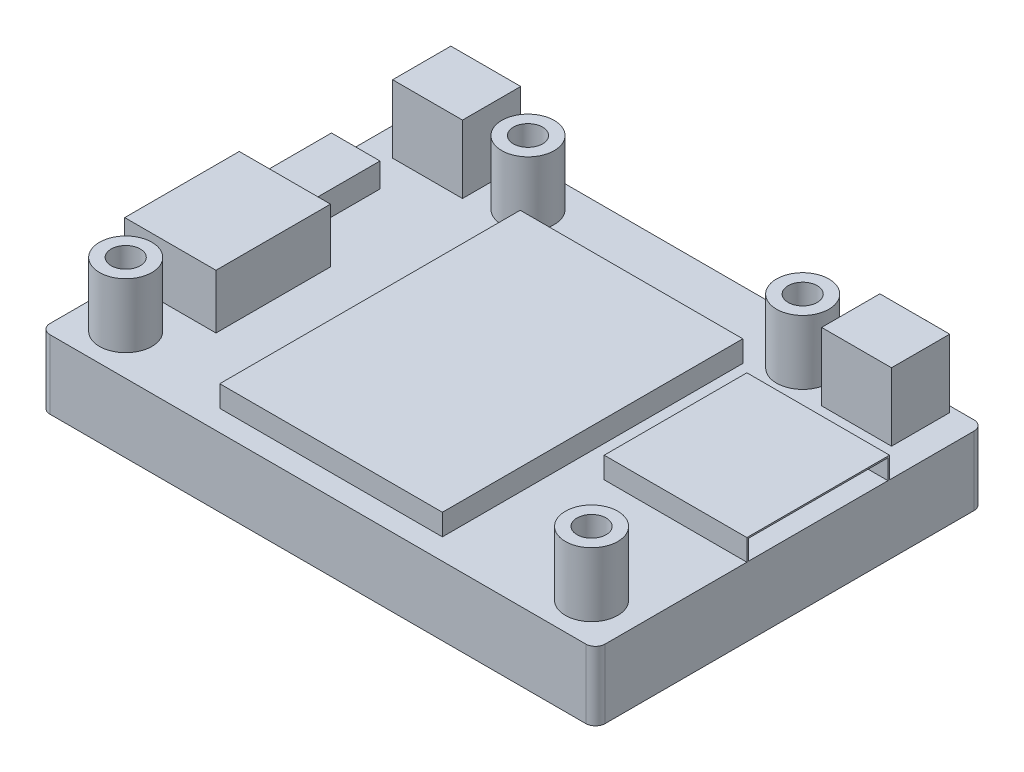
from build123d import *

# Parameters (mm, degrees)
ESBO_O1_W                = 57.2
ESBO_O1_H                = 40
RESSALTO_EXTRUS_O1_DEPTH = 7.1
ESBO_O2_R                = 2.7
RESSALTO_EXTRUS_O2_DEPTH = 6.6
ESBO_O3_R                = 1.5
CORTE_EXTRUS_O1_DEPTH    = 6.6
ESBO_O4_W                = 40.649985971
ESBO_O4_H                = 33.681416947
CORTE_EXTRUS_O2_DEPTH    = 0.1
ESBO_O5_W                = 14.7
ESBO_O5_H                = 14.7
RESSALTO_EXTRUS_O3_DEPTH = 2.2
ESBO_O6_W                = 14.368584986
ESBO_O6_H                = 2.042443489
CORTE_EXTRUS_O3_DEPTH    = 10
ESBO_O7_W                = 9.4
ESBO_O7_H                = 11.8
ESBO_O7_W_2              = 5
ESBO_O7_H_2              = 7.3
RESSALTO_EXTRUS_O4_DEPTH = 2.5
ESBO_O8_W                = 9.4
ESBO_O8_H                = 11.8
RESSALTO_EXTRUS_O5_DEPTH = 3.1
ESBO_O9_W                = 5.766531476
ESBO_O9_H                = 1.868031324
ESBO_O9_W_2              = 10.396000408
ESBO_O9_H_2              = 4.791906438
ESBO_O9_W_3              = 1.746203194
ESBO_O9_H_3              = 2.030468829
ESBO_O9_W_4              = 1.096453168
ESBO_O9_W_5              = 1.218281297
ESBO_O9_W_6              = 0.771578155
CORTE_EXTRUS_O4_DEPTH    = 3.1
FILETE1_R                = 1
ESBO_O10_W               = 22.938206369
ESBO_O10_H               = 30.952060747
RESSALTO_EXTRUS_O6_DEPTH = 2.2
ESBO_O11_W               = 7.2
ESBO_O11_H               = 6
RESSALTO_EXTRUS_O7_DEPTH = 7
ESBO_O12_R               = 2.135826149
ESBO_O12_R_2             = 1.975311567
RESSALTO_EXTRUS_O8_DEPTH = 1.2


with BuildPart() as part:
    # Esboço1 → Ressalto-extrusão1 (new body)
    with BuildSketch(Plane(origin=(0, 0, 0), x_dir=(1, 0, 0), z_dir=(0, 1, 0))):
        with Locations((28.6, 20)):
            Rectangle(ESBO_O1_W, ESBO_O1_H)
    extrude(amount=RESSALTO_EXTRUS_O1_DEPTH)

    # Esboço2 → Ressalto-extrusão2 (add)
    with BuildSketch(Plane(origin=(0, 7.1, 0), x_dir=(1, 0, 0), z_dir=(0, 1, 0))):
        with Locations((4.6, 4.2)):
            Circle(ESBO_O2_R)
        with Locations((52.6, 4.2)):
            Circle(ESBO_O2_R)
        with Locations((42.75, 35.8)):
            Circle(ESBO_O2_R)
        with Locations((14.45, 35.8)):
            Circle(ESBO_O2_R)
    extrude(amount=RESSALTO_EXTRUS_O2_DEPTH)

    # Esboço3 → Corte-extrusão1 (cut)
    with BuildSketch(Plane(origin=(0, 13.7, 0), x_dir=(1, 0, 0), z_dir=(0, 1, 0))):
        with Locations((14.45, 35.8)):
            Circle(ESBO_O3_R)
        with Locations((42.75, 35.8)):
            Circle(ESBO_O3_R)
        with Locations((52.6, 4.2)):
            Circle(ESBO_O3_R)
        with Locations((4.6, 4.2)):
            Circle(ESBO_O3_R)
    extrude(amount=-CORTE_EXTRUS_O1_DEPTH, mode=Mode.SUBTRACT)

    # Esboço4 → Corte-extrusão2 (cut)
    with BuildSketch(Plane(origin=(0, 0, 0), x_dir=(-1, 0, 0), z_dir=(0, -1, 0))):
        with Locations((-23.751037388, 20.174214226)):
            Rectangle(ESBO_O4_W, ESBO_O4_H)
    extrude(amount=-CORTE_EXTRUS_O2_DEPTH, mode=Mode.SUBTRACT)

    # Esboço5 → Ressalto-extrusão3 (add)
    with BuildSketch(Plane(origin=(0, 7.1, 0), x_dir=(1, 0, 0), z_dir=(0, 1, 0))):
        with Locations((49.85, 22.95)):
            Rectangle(ESBO_O5_W, ESBO_O5_H)
    extrude(amount=RESSALTO_EXTRUS_O3_DEPTH)

    # Esboço6 → Corte-extrusão3 (cut)
    with BuildSketch(Plane(origin=(57.2, 0, 0), x_dir=(0, 0, -1), z_dir=(1, 0, 0))):
        with Locations((22.950407173, 8.128512291)):
            Rectangle(ESBO_O6_W, ESBO_O6_H)
    extrude(amount=-CORTE_EXTRUS_O3_DEPTH, mode=Mode.SUBTRACT)

    # Esboço7 → Ressalto-extrusão4 (add)
    with BuildSketch(Plane(origin=(0, 7.1, 0), x_dir=(1, 0, 0), z_dir=(0, 1, 0))):
        with Locations((4.7, 14.6)):
            Rectangle(ESBO_O7_W, ESBO_O7_H)
        with Locations((2.5, 26.35)):
            Rectangle(ESBO_O7_W_2, ESBO_O7_H_2)
    extrude(amount=RESSALTO_EXTRUS_O4_DEPTH)

    # Esboço8 → Ressalto-extrusão5 (add)
    with BuildSketch(Plane(origin=(0, 9.6, 0), x_dir=(1, 0, 0), z_dir=(0, 1, 0))):
        with Locations((4.7, 14.6)):
            Rectangle(ESBO_O8_W, ESBO_O8_H)
    extrude(amount=RESSALTO_EXTRUS_O5_DEPTH)

    # Esboço9 → Corte-extrusão4 (cut)
    with BuildSketch(Plane.ZY):
        with Locations((-26.071101801, 8.149500051)):
            Rectangle(ESBO_O9_W, ESBO_O9_H)
        with Locations((-14.416210718, 9.611437608)):
            Rectangle(ESBO_O9_W_2, ESBO_O9_H_2)
        with Locations((-17.482218651, 9.611437609)):
            Rectangle(ESBO_O9_W_3, ESBO_O9_H_3, mode=Mode.SUBTRACT)
        with Locations((-14.680171666, 9.611437609)):
            Rectangle(ESBO_O9_W_4, ESBO_O9_H_3, mode=Mode.SUBTRACT)
        with Locations((-12.588788772, 9.611437609)):
            Rectangle(ESBO_O9_W_5, ESBO_O9_H_3, mode=Mode.SUBTRACT)
        with Locations((-10.659843384, 9.611437609)):
            Rectangle(ESBO_O9_W_6, ESBO_O9_H_3, mode=Mode.SUBTRACT)
    extrude(amount=-CORTE_EXTRUS_O4_DEPTH, mode=Mode.SUBTRACT)

    # Filete1
    filete1_edges = [part.edges().sort_by_distance(p)[0] for p in [
        (0, 3.55, -40),
        (57.2, 3.55, -40),
        (57.2, 3.55, 0),
        (0, 3.55, 0),
    ]]
    fillet(filete1_edges, radius=FILETE1_R)

    # Esboço10 → Ressalto-extrusão6 (add)
    with BuildSketch(Plane(origin=(0, 7.1, 0), x_dir=(1, 0, 0), z_dir=(0, 1, 0))):
        with Locations((27.787000281, 17.648107954)):
            Rectangle(ESBO_O10_W, ESBO_O10_H)
    extrude(amount=RESSALTO_EXTRUS_O6_DEPTH)

    # Esboço11 → Ressalto-extrusão7 (add)
    with BuildSketch(Plane(origin=(0, 7.1, 0), x_dir=(1, 0, 0), z_dir=(0, 1, 0))):
        with Locations((6.5, 36.4)):
            Rectangle(ESBO_O11_W, ESBO_O11_H)
        with Locations((50.7, 36.4)):
            Rectangle(ESBO_O11_W, ESBO_O11_H)
    extrude(amount=RESSALTO_EXTRUS_O7_DEPTH)

    # Esboço12 → Ressalto-extrusão8 (add)
    with BuildSketch(Plane(origin=(0, 0, -39.4), x_dir=(-1, 0, 0), z_dir=(0, 0, -1))):
        with Locations((-50.742973547, 10.778272234)):
            Circle(ESBO_O12_R)
        with Locations((-6.357026453, 10.778272234)):
            Circle(ESBO_O12_R_2)
    extrude(amount=RESSALTO_EXTRUS_O8_DEPTH)


solid = part.part
